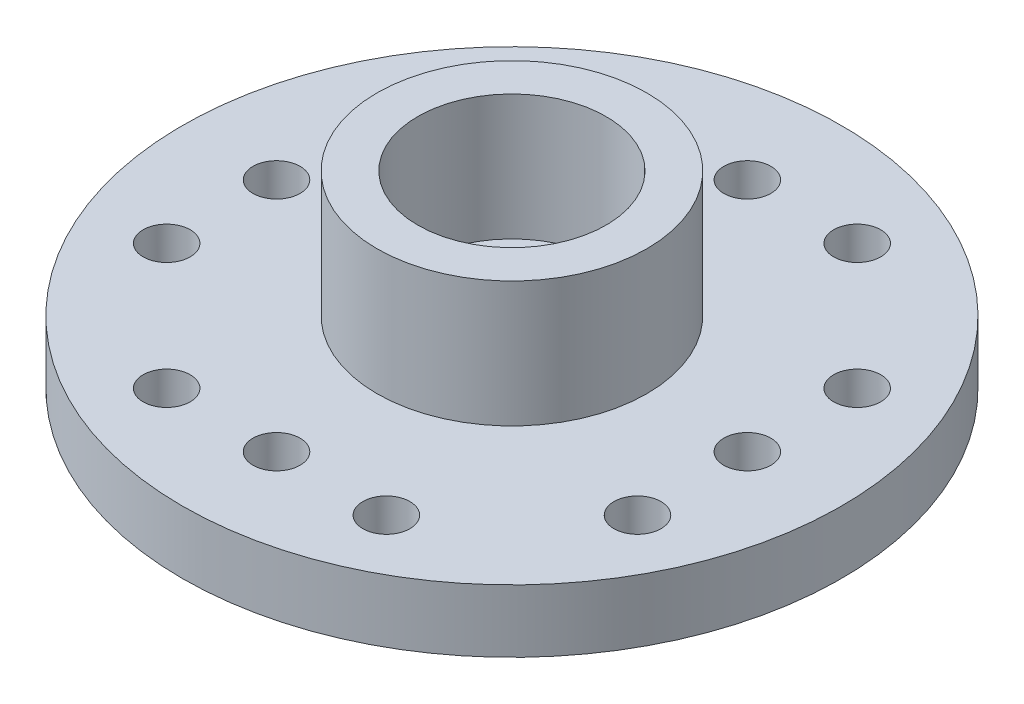
from build123d import *

# Parameters (mm, degrees)
CUT_EXTRUDE_1_REACH = 4
SKETCH_2_R          = 0.75


with BuildPart() as part:
    # 草图1 → 旋转1 (revolve)
    with BuildSketch(Plane.XY):
        Polygon((0, 0), (10.5, 0), (10.5, 2), (4.3, 2), (4.3, 6), (3, 6), (3, 2), (0, 2), align=None)
    revolve(axis=Axis((0, 2, 0), (0, -1, 0)))

    # 草图2 → 切除-拉伸1 (cut, up to next)
    with BuildSketch(Plane(origin=(0, 2, 0), x_dir=(1, 0, 0), z_dir=(0, 1, 0)), mode=Mode.PRIVATE) as cut_extrude_1_sk1:
        with Locations((3.5, 7.5)):
            Circle(SKETCH_2_R)
    cut_extrude_1_tool1 = extrude(cut_extrude_1_sk1.sketch, amount=-CUT_EXTRUDE_1_REACH, mode=Mode.PRIVATE) & part.part
    add(cut_extrude_1_tool1.solids().sort_by_distance((3.5, 2, -7.5))[0], mode=Mode.SUBTRACT)
    # 草图2 → 切除-拉伸1 (cut, up to next)
    with BuildSketch(Plane(origin=(0, 2, 0), x_dir=(1, 0, 0), z_dir=(0, 1, 0)), mode=Mode.PRIVATE) as cut_extrude_1_sk2:
        with Locations((0, 7.5)):
            Circle(SKETCH_2_R)
    cut_extrude_1_tool2 = extrude(cut_extrude_1_sk2.sketch, amount=-CUT_EXTRUDE_1_REACH, mode=Mode.PRIVATE) & part.part
    add(cut_extrude_1_tool2.solids().sort_by_distance((0, 2, -7.5))[0], mode=Mode.SUBTRACT)
    # 草图2 → 切除-拉伸1 (cut, up to next)
    with BuildSketch(Plane(origin=(0, 2, 0), x_dir=(1, 0, 0), z_dir=(0, 1, 0)), mode=Mode.PRIVATE) as cut_extrude_1_sk3:
        with Locations((-3.5, 7.5)):
            Circle(SKETCH_2_R)
    cut_extrude_1_tool3 = extrude(cut_extrude_1_sk3.sketch, amount=-CUT_EXTRUDE_1_REACH, mode=Mode.PRIVATE) & part.part
    add(cut_extrude_1_tool3.solids().sort_by_distance((-3.5, 2, -7.5))[0], mode=Mode.SUBTRACT)
    # 草图2 → 切除-拉伸1 (cut, up to next)
    with BuildSketch(Plane(origin=(0, 2, 0), x_dir=(1, 0, 0), z_dir=(0, 1, 0)), mode=Mode.PRIVATE) as cut_extrude_1_sk4:
        with Locations((7.5, 3.5)):
            Circle(SKETCH_2_R)
    cut_extrude_1_tool4 = extrude(cut_extrude_1_sk4.sketch, amount=-CUT_EXTRUDE_1_REACH, mode=Mode.PRIVATE) & part.part
    add(cut_extrude_1_tool4.solids().sort_by_distance((7.5, 2, -3.5))[0], mode=Mode.SUBTRACT)
    # 草图2 → 切除-拉伸1 (cut, up to next)
    with BuildSketch(Plane(origin=(0, 2, 0), x_dir=(1, 0, 0), z_dir=(0, 1, 0)), mode=Mode.PRIVATE) as cut_extrude_1_sk5:
        with Locations((7.5, -3.5)):
            Circle(SKETCH_2_R)
    cut_extrude_1_tool5 = extrude(cut_extrude_1_sk5.sketch, amount=-CUT_EXTRUDE_1_REACH, mode=Mode.PRIVATE) & part.part
    add(cut_extrude_1_tool5.solids().sort_by_distance((7.5, 2, 3.5))[0], mode=Mode.SUBTRACT)
    # 草图2 → 切除-拉伸1 (cut, up to next)
    with BuildSketch(Plane(origin=(0, 2, 0), x_dir=(1, 0, 0), z_dir=(0, 1, 0)), mode=Mode.PRIVATE) as cut_extrude_1_sk6:
        with Locations((7.5, 0)):
            Circle(SKETCH_2_R)
    cut_extrude_1_tool6 = extrude(cut_extrude_1_sk6.sketch, amount=-CUT_EXTRUDE_1_REACH, mode=Mode.PRIVATE) & part.part
    add(cut_extrude_1_tool6.solids().sort_by_distance((7.5, 2, 0))[0], mode=Mode.SUBTRACT)
    # 草图2 → 切除-拉伸1 (cut, up to next)
    with BuildSketch(Plane(origin=(0, 2, 0), x_dir=(1, 0, 0), z_dir=(0, 1, 0)), mode=Mode.PRIVATE) as cut_extrude_1_sk7:
        with Locations((3.5, -7.5)):
            Circle(SKETCH_2_R)
    cut_extrude_1_tool7 = extrude(cut_extrude_1_sk7.sketch, amount=-CUT_EXTRUDE_1_REACH, mode=Mode.PRIVATE) & part.part
    add(cut_extrude_1_tool7.solids().sort_by_distance((3.5, 2, 7.5))[0], mode=Mode.SUBTRACT)
    # 草图2 → 切除-拉伸1 (cut, up to next)
    with BuildSketch(Plane(origin=(0, 2, 0), x_dir=(1, 0, 0), z_dir=(0, 1, 0)), mode=Mode.PRIVATE) as cut_extrude_1_sk8:
        with Locations((-3.5, -7.5)):
            Circle(SKETCH_2_R)
    cut_extrude_1_tool8 = extrude(cut_extrude_1_sk8.sketch, amount=-CUT_EXTRUDE_1_REACH, mode=Mode.PRIVATE) & part.part
    add(cut_extrude_1_tool8.solids().sort_by_distance((-3.5, 2, 7.5))[0], mode=Mode.SUBTRACT)
    # 草图2 → 切除-拉伸1 (cut, up to next)
    with BuildSketch(Plane(origin=(0, 2, 0), x_dir=(1, 0, 0), z_dir=(0, 1, 0)), mode=Mode.PRIVATE) as cut_extrude_1_sk9:
        with Locations((0, -7.5)):
            Circle(SKETCH_2_R)
    cut_extrude_1_tool9 = extrude(cut_extrude_1_sk9.sketch, amount=-CUT_EXTRUDE_1_REACH, mode=Mode.PRIVATE) & part.part
    add(cut_extrude_1_tool9.solids().sort_by_distance((0, 2, 7.5))[0], mode=Mode.SUBTRACT)
    # 草图2 → 切除-拉伸1 (cut, up to next)
    with BuildSketch(Plane(origin=(0, 2, 0), x_dir=(1, 0, 0), z_dir=(0, 1, 0)), mode=Mode.PRIVATE) as cut_extrude_1_sk10:
        with Locations((-7.5, -3.5)):
            Circle(SKETCH_2_R)
    cut_extrude_1_tool10 = extrude(cut_extrude_1_sk10.sketch, amount=-CUT_EXTRUDE_1_REACH, mode=Mode.PRIVATE) & part.part
    add(cut_extrude_1_tool10.solids().sort_by_distance((-7.5, 2, 3.5))[0], mode=Mode.SUBTRACT)
    # 草图2 → 切除-拉伸1 (cut, up to next)
    with BuildSketch(Plane(origin=(0, 2, 0), x_dir=(1, 0, 0), z_dir=(0, 1, 0)), mode=Mode.PRIVATE) as cut_extrude_1_sk11:
        with Locations((-7.5, 3.5)):
            Circle(SKETCH_2_R)
    cut_extrude_1_tool11 = extrude(cut_extrude_1_sk11.sketch, amount=-CUT_EXTRUDE_1_REACH, mode=Mode.PRIVATE) & part.part
    add(cut_extrude_1_tool11.solids().sort_by_distance((-7.5, 2, -3.5))[0], mode=Mode.SUBTRACT)
    # 草图2 → 切除-拉伸1 (cut, up to next)
    with BuildSketch(Plane(origin=(0, 2, 0), x_dir=(1, 0, 0), z_dir=(0, 1, 0)), mode=Mode.PRIVATE) as cut_extrude_1_sk12:
        with Locations((-7.5, 0)):
            Circle(SKETCH_2_R)
    cut_extrude_1_tool12 = extrude(cut_extrude_1_sk12.sketch, amount=-CUT_EXTRUDE_1_REACH, mode=Mode.PRIVATE) & part.part
    add(cut_extrude_1_tool12.solids().sort_by_distance((-7.5, 2, 0))[0], mode=Mode.SUBTRACT)


solid = part.part
